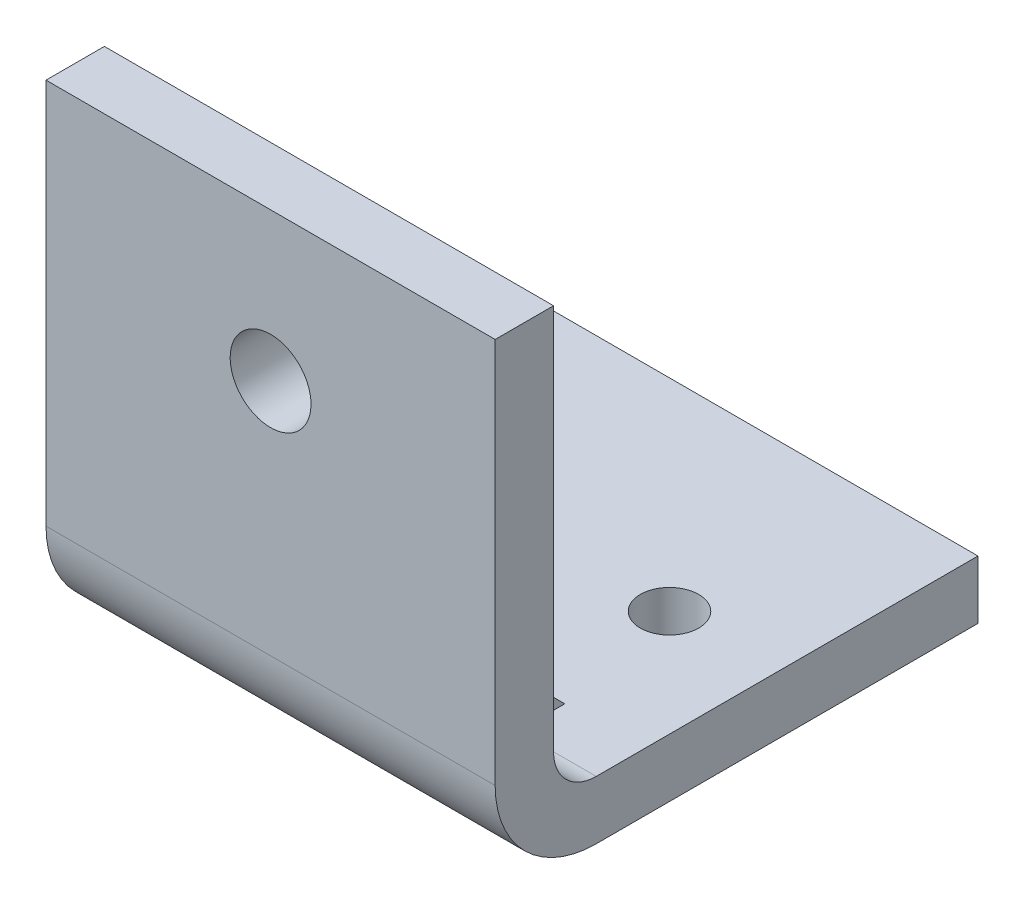
from build123d import *

# Parameters (mm, degrees)
ESTRUSIONE_SOTTILE1_DEPTH = 50
SCHIZZO2_R                = 9
TAGLIO_ESTRUSIONE1_DEPTH  = 148.764170217
SCHIZZO3_R                = 6.5
TAGLIO_ESTRUSIONE2_DEPTH  = 148.720174655
NERVATURA1_REACH          = 166.332
SCHIZZO4_WALL_W           = 358.948233372
SCHIZZO4_WALL_H           = 5


with BuildPart() as part:
    # Schizzo1 → Estrusione-Sottile1 (new, symmetric)
    with BuildSketch(Plane(origin=(0, 0, 0), x_dir=(0, 0, -1), z_dir=(1, 0, 0))):
        with BuildLine():
            Line((-6.5, 102), (-6.5, 16))
            ThreePointArc((-6.5, 16), (0.090097423, 0.090097423), (16, -6.5))
            Line((16, -6.5), (101, -6.5))
            Line((101, -6.5), (101, 6.5))
            Line((101, 6.5), (16, 6.5))
            ThreePointArc((16, 6.5), (9.282485579, 9.282485579), (6.5, 16))
            Line((6.5, 16), (6.5, 102))
            Line((6.5, 102), (-6.5, 102))
        make_face()
    extrude(amount=ESTRUSIONE_SOTTILE1_DEPTH, both=True)

    # Schizzo2 → Taglio-Estrusione1 (cut, through all)
    with BuildSketch(Plane(origin=(0, 0, -6.5), x_dir=(-1, 0, 0), z_dir=(0, 0, -1))):
        with Locations(Location((0, 69, 0), (0, 0, 90))):
            Circle(SCHIZZO2_R)
    extrude(amount=-TAGLIO_ESTRUSIONE1_DEPTH, mode=Mode.SUBTRACT)

    # Schizzo3 → Taglio-Estrusione2 (cut, through all)
    with BuildSketch(Plane(origin=(0, 6.5, 0), x_dir=(1, 0, 0), z_dir=(0, 1, 0))):
        with Locations(Location((-23.683594655, 56, 0), (0, 0, 270))):
            Circle(SCHIZZO3_R)
        with Locations(Location((26.316405345, 56, 0), (0, 0, 270))):
            Circle(SCHIZZO3_R)
    extrude(amount=-TAGLIO_ESTRUSIONE2_DEPTH, mode=Mode.SUBTRACT)

    # Schizzo4 wall → Nervatura1 (add, up to next)
    with BuildSketch(Plane(origin=(30, 16.5, -16.5), x_dir=(0, -0.707106781187, -0.707106781187), z_dir=(0, 0.707106781187, -0.707106781187)), mode=Mode.PRIVATE) as nervatura1_sk1:
        Rectangle(SCHIZZO4_WALL_W, SCHIZZO4_WALL_H)
    nervatura1_tool1 = extrude(nervatura1_sk1.sketch, amount=-NERVATURA1_REACH, mode=Mode.PRIVATE) - part.part
    nervatura1 = nervatura1_tool1.solids().sort_by_distance((30, 16.5, -16.5))[0]
    add(nervatura1)

    # Specchia1: Nervatura1 across plane
    add(nervatura1.mirror(Plane(origin=(0, 0, 0), x_dir=(0, 0, 1), z_dir=(1, 0, 0))))


solid = part.part
